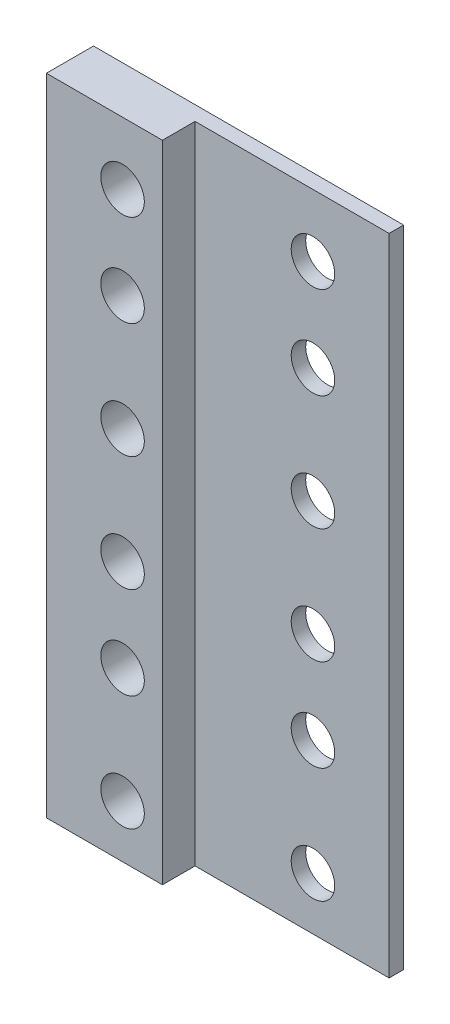
from build123d import *

# Parameters (mm, degrees)
SKETCH1_W           = 42.75
SKETCH1_H           = 88.9
SKETCH1_W_2         = 9.5
SKETCH1_H_2         = 9.5
BOSS_EXTRUDE1_DEPTH = 2
SKETCH2_W           = 9.5
SKETCH2_H           = 9.5
SKETCH2_R           = 3
BOSS_EXTRUDE2_DEPTH = 2
SKETCH3_W           = 16
SKETCH3_H           = 88.9
SKETCH3_R           = 3
BOSS_EXTRUDE3_DEPTH = 6.5


with BuildPart() as part:
    # Sketch1 → Boss-Extrude1 (new body)
    with BuildSketch(Plane.XY):
        with Locations((-3.875, 44.45)):
            Rectangle(SKETCH1_W, SKETCH1_H)
        with Locations((7, 67.59)):
            Rectangle(SKETCH1_W_2, SKETCH1_H_2, mode=Mode.SUBTRACT)
        with Locations((7, 80.29)):
            Rectangle(SKETCH1_W_2, SKETCH1_H_2, mode=Mode.SUBTRACT)
        with Locations((-14.75, 80.29)):
            Rectangle(SKETCH1_W_2, SKETCH1_H_2, mode=Mode.SUBTRACT)
        with Locations((-14.75, 67.59)):
            Rectangle(SKETCH1_W_2, SKETCH1_H_2, mode=Mode.SUBTRACT)
        with Locations((-14.75, 7.25)):
            Rectangle(SKETCH1_W_2, SKETCH1_H_2, mode=Mode.SUBTRACT)
        with Locations((7, 51.71)):
            Rectangle(SKETCH1_W_2, SKETCH1_H_2, mode=Mode.SUBTRACT)
        with Locations((-14.75, 51.71)):
            Rectangle(SKETCH1_W_2, SKETCH1_H_2, mode=Mode.SUBTRACT)
        with Locations((7, 7.25)):
            Rectangle(SKETCH1_W_2, SKETCH1_H_2, mode=Mode.SUBTRACT)
        with Locations((7, 23.13)):
            Rectangle(SKETCH1_W_2, SKETCH1_H_2, mode=Mode.SUBTRACT)
        with Locations((-14.75, 23.13)):
            Rectangle(SKETCH1_W_2, SKETCH1_H_2, mode=Mode.SUBTRACT)
        with Locations((7, 35.83)):
            Rectangle(SKETCH1_W_2, SKETCH1_H_2, mode=Mode.SUBTRACT)
        with Locations((-14.75, 35.83)):
            Rectangle(SKETCH1_W_2, SKETCH1_H_2, mode=Mode.SUBTRACT)
    extrude(amount=BOSS_EXTRUDE1_DEPTH)

    # Sketch2 → Boss-Extrude2 (add)
    with BuildSketch(Plane(origin=(0, 0, 0), x_dir=(-1, 0, 0), z_dir=(0, 0, -1))):
        with Locations((-7, 80.29)):
            Rectangle(SKETCH2_W, SKETCH2_H)
        with Locations((-7, 80.29)):
            Circle(SKETCH2_R, mode=Mode.SUBTRACT)
        with Locations((14.75, 80.29)):
            Rectangle(SKETCH2_W, SKETCH2_H)
        with Locations((14.75, 80.29)):
            Circle(SKETCH2_R, mode=Mode.SUBTRACT)
        with Locations((-7, 67.59)):
            Rectangle(SKETCH2_W, SKETCH2_H)
        with Locations((-7, 67.59)):
            Circle(SKETCH2_R, mode=Mode.SUBTRACT)
        with Locations((14.75, 67.59)):
            Rectangle(SKETCH2_W, SKETCH2_H)
        with Locations((14.75, 67.59)):
            Circle(SKETCH2_R, mode=Mode.SUBTRACT)
        with Locations((-7, 51.71)):
            Rectangle(SKETCH2_W, SKETCH2_H)
        with Locations((-7, 51.71)):
            Circle(SKETCH2_R, mode=Mode.SUBTRACT)
        with Locations((14.75, 51.71)):
            Rectangle(SKETCH2_W, SKETCH2_H)
        with Locations((14.75, 51.71)):
            Circle(SKETCH2_R, mode=Mode.SUBTRACT)
        with Locations((-7, 35.83)):
            Rectangle(SKETCH2_W, SKETCH2_H)
        with Locations((-7, 35.83)):
            Circle(SKETCH2_R, mode=Mode.SUBTRACT)
        with Locations((14.75, 35.83)):
            Rectangle(SKETCH2_W, SKETCH2_H)
        with Locations((14.75, 35.83)):
            Circle(SKETCH2_R, mode=Mode.SUBTRACT)
        with Locations((-7, 23.13)):
            Rectangle(SKETCH2_W, SKETCH2_H)
        with Locations((-7, 23.13)):
            Circle(SKETCH2_R, mode=Mode.SUBTRACT)
        with Locations((14.75, 23.13)):
            Rectangle(SKETCH2_W, SKETCH2_H)
        with Locations((14.75, 23.13)):
            Circle(SKETCH2_R, mode=Mode.SUBTRACT)
        with Locations((14.75, 7.25)):
            Rectangle(SKETCH2_W, SKETCH2_H)
        with Locations((14.75, 7.25)):
            Circle(SKETCH2_R, mode=Mode.SUBTRACT)
        with Locations((-7, 7.25)):
            Rectangle(SKETCH2_W, SKETCH2_H)
        with Locations((-7, 7.25)):
            Circle(SKETCH2_R, mode=Mode.SUBTRACT)
    extrude(amount=-BOSS_EXTRUDE2_DEPTH)

    # Sketch3 → Boss-Extrude3 (add)
    with BuildSketch(Plane(origin=(0, 0, 0), x_dir=(-1, 0, 0), z_dir=(0, 0, -1))):
        with Locations((17.25, 44.45)):
            Rectangle(SKETCH3_W, SKETCH3_H)
        with Locations((14.75, 80.29)):
            Circle(SKETCH3_R, mode=Mode.SUBTRACT)
        with Locations((14.75, 67.59)):
            Circle(SKETCH3_R, mode=Mode.SUBTRACT)
        with Locations((14.75, 51.71)):
            Circle(SKETCH3_R, mode=Mode.SUBTRACT)
        with Locations((14.75, 35.83)):
            Circle(SKETCH3_R, mode=Mode.SUBTRACT)
        with Locations((14.75, 23.13)):
            Circle(SKETCH3_R, mode=Mode.SUBTRACT)
        with Locations((14.75, 7.25)):
            Circle(SKETCH3_R, mode=Mode.SUBTRACT)
    extrude(amount=-BOSS_EXTRUDE3_DEPTH)


solid = part.part
